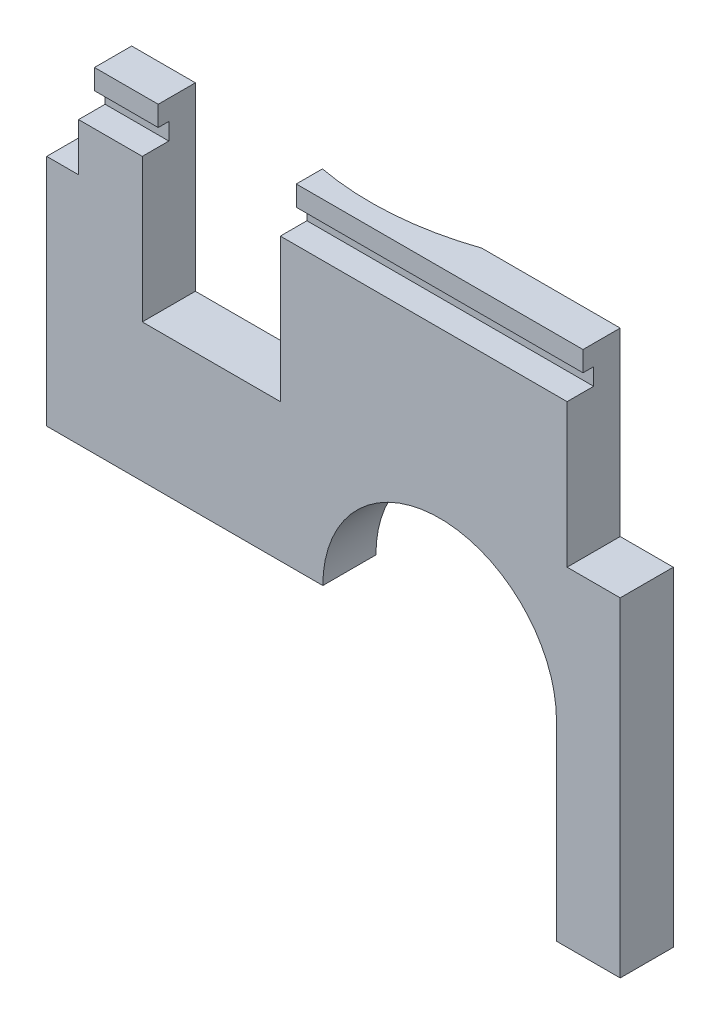
from build123d import *

# Parameters (mm, degrees)
SKETCH_1_W                            = 54
SKETCH_1_H                            = 48
EXTRUDE_1_DEPTH                       = 5
SKETCH_3_W                            = 3
SKETCH_3_H                            = 8
SKETCH_3_W_2                          = 13
SKETCH_3_H_2                          = 17
SKETCH_3_W_3                          = 5
CUT_EXTRUDE_1_DEPTH                   = 6
CUT_EXTRUDE_2_DEPTH                   = 55
CUT_EXTRUDE_3_DEPTH                   = 6
CUT_EXTRUDE_4_DEPTH                   = 12
HOLE_WIZARD_M31_D                     = 2.5
HOLE_WIZARD_M31_DEPTH                 = 7.5
HOLE_WIZARD_M31_CSINK_D               = 3.2
HOLE_WIZARD_M31_CSINK_ANGLE           = 110
HOLE_WIZARD_M31_TIP                   = 0.751075774
HOLE_WIZARD_M31_ON_FACE_2_D           = 2.5
HOLE_WIZARD_M31_ON_FACE_2_DEPTH       = 7.5
HOLE_WIZARD_M31_ON_FACE_2_CSINK_D     = 3.2
HOLE_WIZARD_M31_ON_FACE_2_CSINK_ANGLE = 110
HOLE_WIZARD_M31_ON_FACE_2_TIP         = 0.751075774


with BuildPart() as part:
    # Эскиз1 → Бобышка-Вытянуть1 (new body)
    with BuildSketch(Plane.XY):
        with Locations((27, 24)):
            Rectangle(SKETCH_1_W, SKETCH_1_H)
    extrude(amount=EXTRUDE_1_DEPTH)

    # Эскиз3 → Вырез-Вытянуть1 (cut, through all)
    with BuildSketch(Plane.XY.offset(5)):
        with Locations((1.5, 44)):
            Rectangle(SKETCH_3_W, SKETCH_3_H)
        with Locations((15.5, 39.5)):
            Rectangle(SKETCH_3_W_2, SKETCH_3_H_2)
        with Locations((51.5, 39.5)):
            Rectangle(SKETCH_3_W_3, SKETCH_3_H_2)
    extrude(amount=-CUT_EXTRUDE_1_DEPTH, mode=Mode.SUBTRACT)

    # Эскиз4 → Вырез-Вытянуть2 (cut, through all)
    with BuildSketch(Plane.ZY):
        Polygon((3.5, 154.254870007), (3.5, 48), (3.5, 46.1), (2.5, 46.1), (2.5, 44.5), (5, 44.5), (111.254870007, 44.5), (262.897242217, 193.3790803), (155.14237221, 303.133950307), align=None)
    extrude(amount=-CUT_EXTRUDE_2_DEPTH, mode=Mode.SUBTRACT)

    # Эскиз5 → Вырез-Вытянуть3 (cut, through all)
    with BuildSketch(Plane.XY.offset(5)):
        with BuildLine():
            Line((48, -145.764501988), (48, 0))
            Line((48, 0), (48, 18))
            ThreePointArc((48, 18), (37, 29), (26, 18))
            Line((26, 18), (0, 18))
            Line((0, 18), (-145.764501988, 18))
            Line((-145.764501988, 18), (-333.948083842, -204.656910244))
            Line((-333.948083842, -204.656910244), (-140.183581854, -368.421412232))
            Line((-140.183581854, -368.421412232), (48, -145.764501988))
        make_face()
    extrude(amount=-CUT_EXTRUDE_3_DEPTH, mode=Mode.SUBTRACT)

    # Эскиз6 → Вырез-Вытянуть4 (cut)
    with BuildSketch(Plane(origin=(0, 48, 0), x_dir=(1, 0, 0), z_dir=(0, 1, 0))):
        with BuildLine():
            ThreePointArc((35.958236434, 0), (49.389746559, 10.032869731), (54.5, 26))
            ThreePointArc((54.5, 26), (4.610253441, 41.967130269), (35.958236434, 0))
        make_face()
    extrude(amount=-CUT_EXTRUDE_4_DEPTH, mode=Mode.SUBTRACT)

    # Отверстие обработанное метчиком M31
    with Locations(Plane(origin=(0, 22, 2.5), x_dir=(0, 0, -1), z_dir=(-1, 0, 0))):
        with Locations((0, 0), (0, -12)):
            CounterSinkHole(HOLE_WIZARD_M31_D / 2, HOLE_WIZARD_M31_CSINK_D / 2, depth=HOLE_WIZARD_M31_DEPTH, counter_sink_angle=HOLE_WIZARD_M31_CSINK_ANGLE)
            with Locations((0, 0, -(HOLE_WIZARD_M31_DEPTH + HOLE_WIZARD_M31_TIP / 2))):  # 118° drill point
                Cone(0, HOLE_WIZARD_M31_D / 2, HOLE_WIZARD_M31_TIP, mode=Mode.SUBTRACT)

    # Отверстие обработанное метчиком M31 on face 2
    with Locations(Plane(origin=(51, 0, 2.5), x_dir=(0, 0, -1), z_dir=(0, -1, 0))):
        with Locations((0, 0)):
            CounterSinkHole(HOLE_WIZARD_M31_ON_FACE_2_D / 2, HOLE_WIZARD_M31_ON_FACE_2_CSINK_D / 2, depth=HOLE_WIZARD_M31_ON_FACE_2_DEPTH, counter_sink_angle=HOLE_WIZARD_M31_ON_FACE_2_CSINK_ANGLE)
            with Locations((0, 0, -(HOLE_WIZARD_M31_ON_FACE_2_DEPTH + HOLE_WIZARD_M31_ON_FACE_2_TIP / 2))):  # 118° drill point
                Cone(0, HOLE_WIZARD_M31_ON_FACE_2_D / 2, HOLE_WIZARD_M31_ON_FACE_2_TIP, mode=Mode.SUBTRACT)

    # Эскиз10 → Вырез-Повернуть1 (revolve, cut)
    with BuildSketch(Plane(origin=(1.455771366, -2.52146997, 0), x_dir=(0, 0, -1), z_dir=(-0.5, 0.866025404, 0))):
        Polygon((-6.082903769, -46.04293994), (2, -60.04293994), (2, -46.04293994), align=None)
    revolve(axis=Axis((41.330127019, 20.5, 5.306460427), (0, 0, -1)), mode=Mode.SUBTRACT)


solid = part.part
